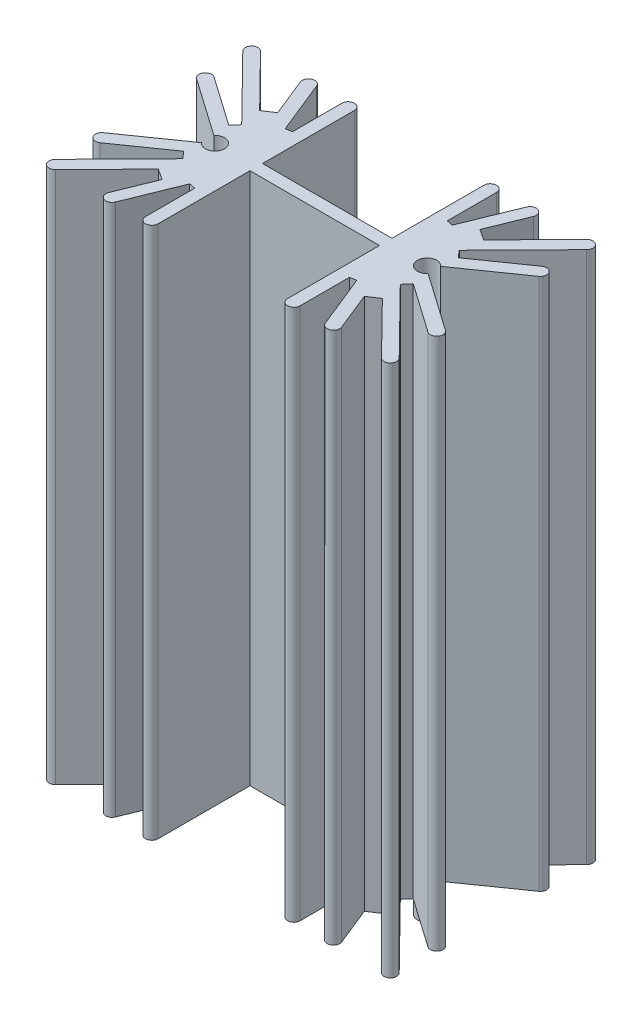
from build123d import *

# Parameters (mm, degrees)
BOSS_EXTRUDE1_DEPTH        = 63.75
CUT_EXTRUDE1_REACH         = 15.25
SKETCH2_R                  = 1.58
SKETCH3_R                  = 1.15
BOSS_EXTRUDE2_DEPTH        = 3.5
BOSS_EXTRUDE2_DEPTH_BACK   = 3.5
BOSS_EXTRUDE2_2_DEPTH      = 3.5
BOSS_EXTRUDE2_2_DEPTH_BACK = 3.5


with BuildPart() as part:
    # Sketch1 → Boss-Extrude1 (new body)
    with BuildSketch(Plane(origin=(0, 0, 0), x_dir=(1, 0, 0), z_dir=(0, 1, 0))):
        with BuildLine():
            Line((7.75, 11.75), (7.75, 0.75))
            Line((7.75, 0.75), (-7.75, 0.75))
            Line((-7.75, 0.75), (-7.75, 11.75))
            ThreePointArc((-7.75, 11.75), (-8.5, 12.5), (-9.25, 11.75))
            Line((-9.25, 11.75), (-9.25, 5.858415512))
            Line((-9.25, 5.858415512), (-9.999213187, 5.712783221))
            Line((-9.999213187, 5.712783221), (-12.551920263, 12.030954945))
            ThreePointArc((-12.551920263, 12.030954945), (-13.528263099, 12.445387891), (-13.942696044, 11.469045055))
            Line((-13.942696044, 11.469045055), (-12.10574193, 6.922424076))
            Line((-12.10574193, 6.922424076), (-13.411361038, 6.06628904))
            Line((-13.411361038, 6.06628904), (-19.515137428, 12.275758528))
            ThreePointArc((-19.515137428, 12.275758528), (-20.575758528, 12.284862572), (-20.584862572, 11.224241472))
            Line((-20.584862572, 11.224241472), (-13.020617465, 3.529013766))
            Line((-13.020617465, 3.529013766), (-13.729461508, 2.691571812))
            Line((-13.729461508, 2.691571812), (-19.619817673, 6.816043601))
            ThreePointArc((-19.619817673, 6.816043601), (-20.664364033, 6.631861895), (-20.480182327, 5.587315534))
            Line((-20.480182327, 5.587315534), (-13.571779789, 0.75))
            ThreePointArc((-13.571779789, 0.75), (-11.55, 0), (-13.571779789, -0.75))
            Line((-13.571779789, -0.75), (-20.480182327, -5.587315534))
            ThreePointArc((-20.480182327, -5.587315534), (-20.664364033, -6.631861895), (-19.619817673, -6.816043601))
            Line((-19.619817673, -6.816043601), (-13.729461508, -2.691571812))
            Line((-13.729461508, -2.691571812), (-13.020617465, -3.529013766))
            Line((-13.020617465, -3.529013766), (-20.584862572, -11.224241472))
            ThreePointArc((-20.584862572, -11.224241472), (-20.575758528, -12.284862572), (-19.515137428, -12.275758528))
            Line((-19.515137428, -12.275758528), (-13.411361038, -6.06628904))
            Line((-13.411361038, -6.06628904), (-12.10574193, -6.922424076))
            Line((-12.10574193, -6.922424076), (-13.942696044, -11.469045055))
            ThreePointArc((-13.942696044, -11.469045055), (-13.528263099, -12.445387891), (-12.551920263, -12.030954945))
            Line((-12.551920263, -12.030954945), (-9.999213187, -5.712783221))
            Line((-9.999213187, -5.712783221), (-9.25, -5.858415512))
            Line((-9.25, -5.858415512), (-9.25, -11.75))
            ThreePointArc((-9.25, -11.75), (-8.5, -12.5), (-7.75, -11.75))
            Line((-7.75, -11.75), (-7.75, -0.75))
            Line((-7.75, -0.75), (7.75, -0.75))
            Line((7.75, -0.75), (7.75, -11.75))
            ThreePointArc((7.75, -11.75), (8.5, -12.5), (9.25, -11.75))
            Line((9.25, -11.75), (9.25, -5.858415512))
            Line((9.25, -5.858415512), (9.999213187, -5.712783221))
            Line((9.999213187, -5.712783221), (12.551920263, -12.030954945))
            ThreePointArc((12.551920263, -12.030954945), (13.528263099, -12.445387891), (13.942696044, -11.469045055))
            Line((13.942696044, -11.469045055), (12.10574193, -6.922424076))
            Line((12.10574193, -6.922424076), (13.411361038, -6.06628904))
            Line((13.411361038, -6.06628904), (19.515137428, -12.275758528))
            ThreePointArc((19.515137428, -12.275758528), (20.575758528, -12.284862572), (20.584862572, -11.224241472))
            Line((20.584862572, -11.224241472), (13.020617465, -3.529013766))
            Line((13.020617465, -3.529013766), (13.729461508, -2.691571812))
            Line((13.729461508, -2.691571812), (19.619817673, -6.816043601))
            ThreePointArc((19.619817673, -6.816043601), (20.664364033, -6.631861895), (20.480182327, -5.587315534))
            Line((20.480182327, -5.587315534), (13.571779789, -0.75))
            ThreePointArc((13.571779789, -0.75), (11.55, 0), (13.571779789, 0.75))
            Line((13.571779789, 0.75), (20.480182327, 5.587315534))
            ThreePointArc((20.480182327, 5.587315534), (20.664364033, 6.631861895), (19.619817673, 6.816043601))
            Line((19.619817673, 6.816043601), (13.729461508, 2.691571812))
            Line((13.729461508, 2.691571812), (13.020617465, 3.529013766))
            Line((13.020617465, 3.529013766), (20.584862572, 11.224241472))
            ThreePointArc((20.584862572, 11.224241472), (20.575758528, 12.284862572), (19.515137428, 12.275758528))
            Line((19.515137428, 12.275758528), (13.411361038, 6.06628904))
            Line((13.411361038, 6.06628904), (12.10574193, 6.922424076))
            Line((12.10574193, 6.922424076), (13.942696044, 11.469045055))
            ThreePointArc((13.942696044, 11.469045055), (13.528263099, 12.445387891), (12.551920263, 12.030954945))
            Line((12.551920263, 12.030954945), (9.999213187, 5.712783221))
            Line((9.999213187, 5.712783221), (9.25, 5.858415512))
            Line((9.25, 5.858415512), (9.25, 11.75))
            ThreePointArc((9.25, 11.75), (8.5, 12.5), (7.75, 11.75))
        make_face()
    extrude(amount=BOSS_EXTRUDE1_DEPTH)

    # Sketch2 → Cut-Extrude1 (cut, up to next)
    with BuildSketch(Plane.XY.offset(0.75), mode=Mode.PRIVATE) as cut_extrude1_sk1:
        with Locations((0, 13.2)):
            Circle(SKETCH2_R)
    cut_extrude1_tool1 = extrude(cut_extrude1_sk1.sketch, amount=-CUT_EXTRUDE1_REACH, mode=Mode.PRIVATE) & part.part
    add(cut_extrude1_tool1.solids().sort_by_distance((0, 13.2, 0.75))[0], mode=Mode.SUBTRACT)
    # Sketch2 → Cut-Extrude1 (cut, up to next)
    with BuildSketch(Plane.XY.offset(0.75), mode=Mode.PRIVATE) as cut_extrude1_sk2:
        with Locations((0, 18.3)):
            Circle(SKETCH2_R)
    cut_extrude1_tool2 = extrude(cut_extrude1_sk2.sketch, amount=-CUT_EXTRUDE1_REACH, mode=Mode.PRIVATE) & part.part
    add(cut_extrude1_tool2.solids().sort_by_distance((0, 18.3, 0.75))[0], mode=Mode.SUBTRACT)
    # Sketch2 → Cut-Extrude1 (cut, up to next)
    with BuildSketch(Plane.XY.offset(0.75), mode=Mode.PRIVATE) as cut_extrude1_sk3:
        with Locations((0, 25.4)):
            Circle(SKETCH2_R)
    cut_extrude1_tool3 = extrude(cut_extrude1_sk3.sketch, amount=-CUT_EXTRUDE1_REACH, mode=Mode.PRIVATE) & part.part
    add(cut_extrude1_tool3.solids().sort_by_distance((0, 25.4, 0.75))[0], mode=Mode.SUBTRACT)


with BuildPart() as body_2:
    # Sketch3 → Boss-Extrude2 (new body, two sides)
    with BuildSketch(Plane.XZ) as boss_extrude2_sk:
        with Locations((-12.7, 0)):
            Circle(SKETCH3_R)
    extrude(amount=BOSS_EXTRUDE2_DEPTH)
    extrude(boss_extrude2_sk.sketch, amount=-BOSS_EXTRUDE2_DEPTH_BACK)


with BuildPart() as body_3:
    # Sketch3 → Boss-Extrude2 2 (new body, two sides)
    with BuildSketch(Plane.XZ) as boss_extrude2_2_sk:
        with Locations((12.7, 0)):
            Circle(SKETCH3_R)
    extrude(amount=BOSS_EXTRUDE2_2_DEPTH)
    extrude(boss_extrude2_2_sk.sketch, amount=-BOSS_EXTRUDE2_2_DEPTH_BACK)


solid = Compound([part.part, body_2.part, body_3.part])
